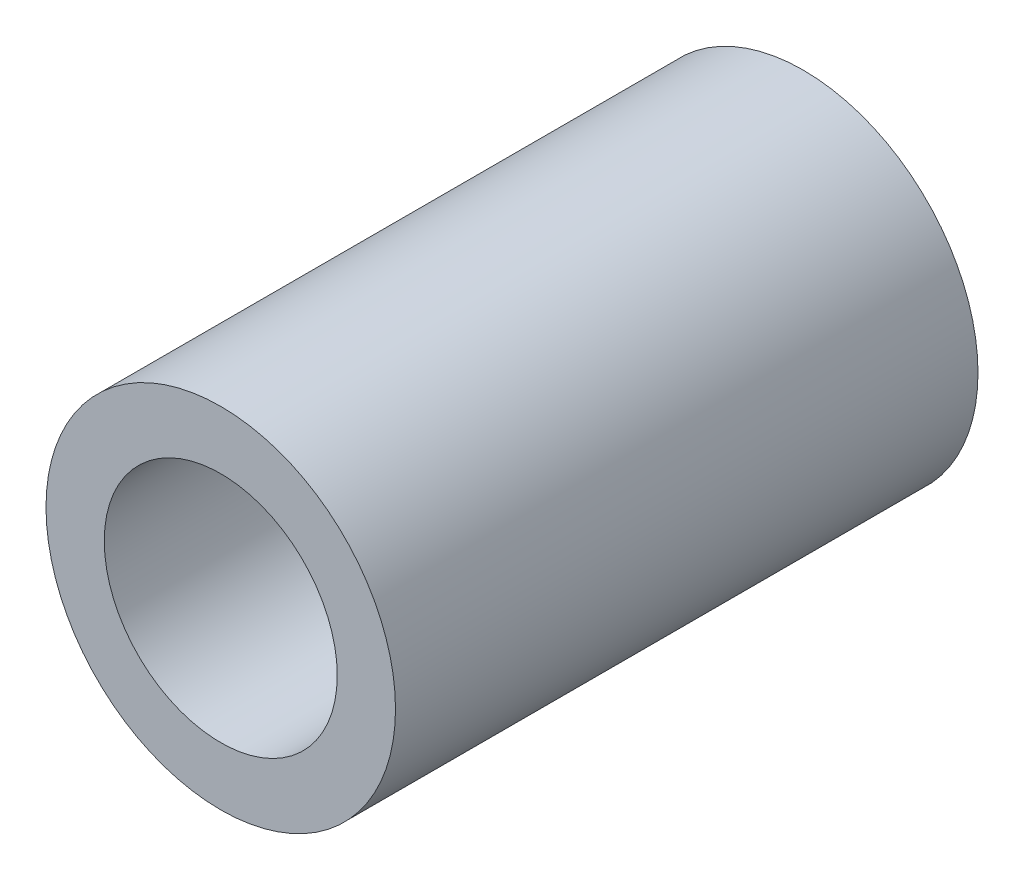
from build123d import *

# Parameters (mm, degrees)
SKETCH1_R           = 4.5
SKETCH1_R_2         = 3
BOSS_EXTRUDE1_DEPTH = 15


with BuildPart() as part:
    # Sketch1 → Boss-Extrude1 (new body)
    with BuildSketch(Plane.XY):
        Circle(SKETCH1_R)
        Circle(SKETCH1_R_2, mode=Mode.SUBTRACT)
    extrude(amount=BOSS_EXTRUDE1_DEPTH)


solid = part.part
